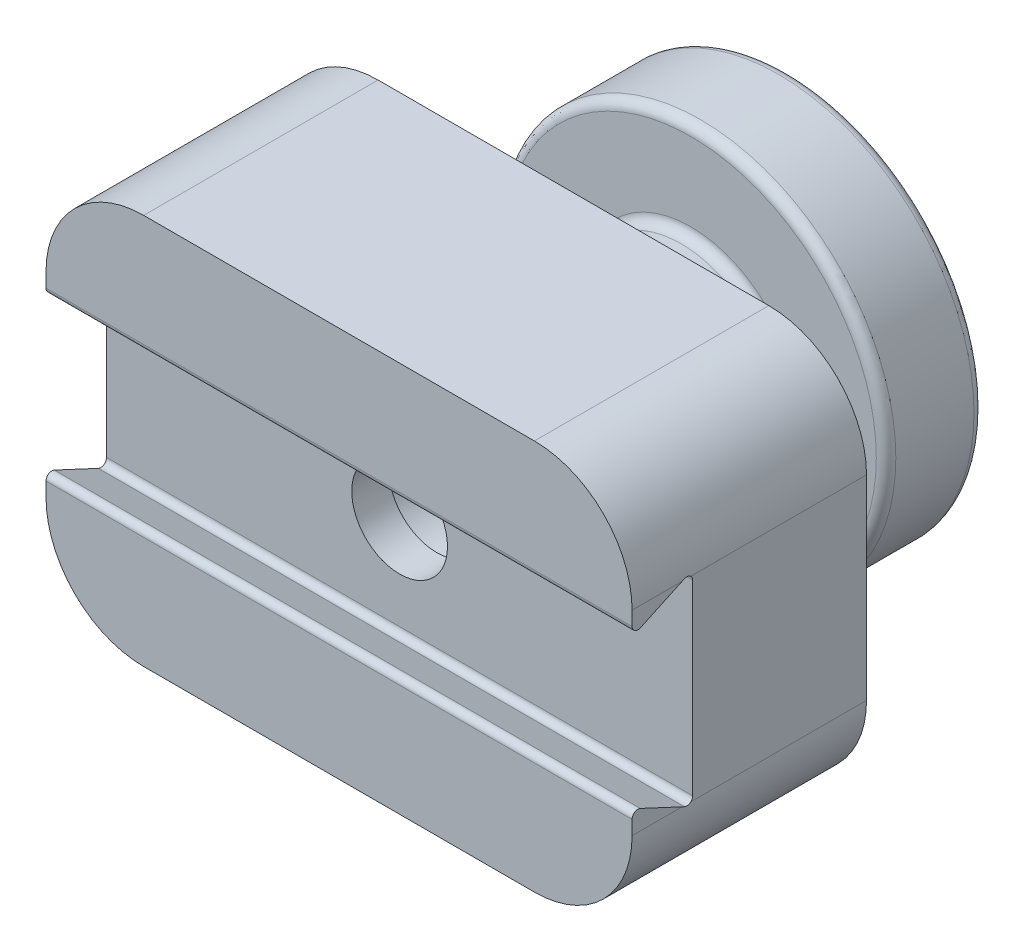
from build123d import *

# Parameters (mm, degrees)
BOSS_EXTRUDE1_DEPTH     = 5
SKETCH2_R               = 5
BOSS_EXTRUDE2_DEPTH     = 11
SKETCH3_W               = 30
SKETCH3_H               = 20
BOSS_EXTRUDE3_DEPTH     = 12
CUT_EXTRUDE1_DEPTH      = 26
CUT_EXTRUDE1_DEPTH_BACK = 6
SKETCH6_R               = 2.45
CUT_EXTRUDE2_DEPTH      = 5
FILLET1_R               = 0.3
FILLET2_R               = 5
FILLET3_R               = 0.5
SKETCH7_R               = 2.9
CUT_EXTRUDE3_DEPTH      = 6


with BuildPart() as part:
    # Sketch1 → Boss-Extrude1 (new body)
    with BuildSketch(Plane.XY):
        with BuildLine():
            ThreePointArc((10, 0), (0, 10), (-10, 0))
            ThreePointArc((-10, 0), (0, -10), (10, 0))
        make_face()
    extrude(amount=BOSS_EXTRUDE1_DEPTH)

    # Sketch2 → Boss-Extrude2 (add)
    with BuildSketch(Plane.XY):
        Circle(SKETCH2_R)
    extrude(amount=BOSS_EXTRUDE2_DEPTH)

    # Sketch3 → Boss-Extrude3 (add)
    with BuildSketch(Plane.XY.offset(11)):
        Rectangle(SKETCH3_W, SKETCH3_H)
    extrude(amount=BOSS_EXTRUDE3_DEPTH)

    # Sketch5 → Cut-Extrude1 (cut, two sides)
    with BuildSketch(Plane(origin=(-10, 0, 0), x_dir=(0, 0, -1), z_dir=(1, 0, 0))) as cut_extrude1_sk:
        Polygon((-23, 3.80444626), (-19.9, 5.25), (-19.9, -5.25), (-23, -3.80444626), align=None)
    extrude(amount=CUT_EXTRUDE1_DEPTH, mode=Mode.SUBTRACT)
    extrude(cut_extrude1_sk.sketch, amount=-CUT_EXTRUDE1_DEPTH_BACK, mode=Mode.SUBTRACT)

    # Sketch6 → Cut-Extrude2 (cut)
    with BuildSketch(Plane.XY.offset(23)):
        Circle(SKETCH6_R)
    extrude(amount=-CUT_EXTRUDE2_DEPTH, mode=Mode.SUBTRACT)

    # Fillet1
    fillet1_edges = [part.edges().sort_by_distance(p)[0] for p in [
        (0, 3.80444626, 23),
        (0, -3.80444626, 23),
        (0, -5.25, 19.9),
        (0, 5.25, 19.9),
    ]]
    fillet(fillet1_edges, radius=FILLET1_R)

    # Fillet2
    fillet2_edges = [part.edges().sort_by_distance(p)[0] for p in [
        (15, -10, 17),
        (15, 10, 17),
        (-15, 10, 17),
        (-15, -10, 17),
    ]]
    fillet(fillet2_edges, radius=FILLET2_R)

    # Fillet3
    fillet3_edges = [part.edges().sort_by_distance(p)[0] for p in [
        (-5, 0, 11),
        (10, 0, 0),
        (10, 0, 5),
        (-5, 0, 5),
    ]]
    fillet(fillet3_edges, radius=FILLET3_R)

    # Sketch7 → Cut-Extrude3 (cut)
    with BuildSketch(Plane.XY.offset(18)):
        Circle(SKETCH7_R)
    extrude(amount=-CUT_EXTRUDE3_DEPTH, mode=Mode.SUBTRACT)


solid = part.part
